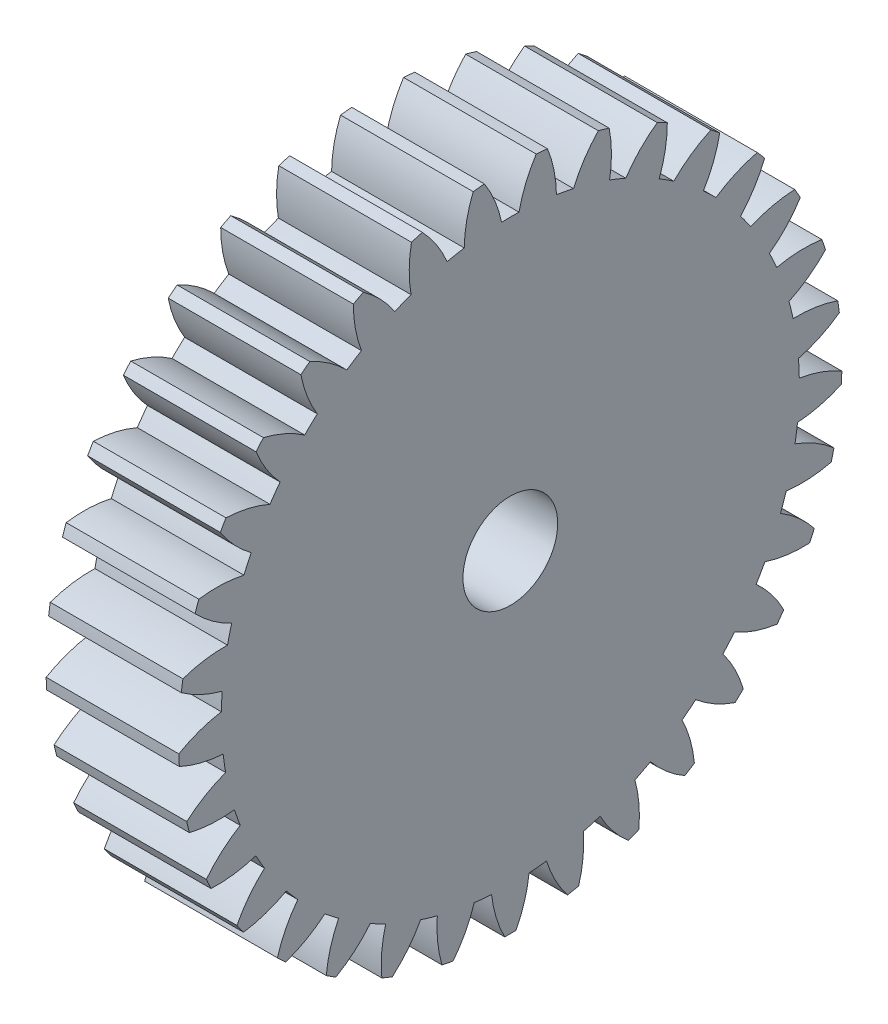
from build123d import *

# Parameters (mm, degrees)
BASPROSKE_W     = 7
BASPROSKE_H     = 17.5
TOOTHCUT_DEPTH  = 26.719642299
TEETHCUTS_COUNT = 33
TEETHCUTS_ANGLE = 349.090909091
BORSKE_R        = 2.5
BORE_DEPTH      = 50.0000508


with BuildPart() as part:
    # BasProSke → Base-Revolve (revolve)
    with BuildSketch(Plane(origin=(0, 0, 0), x_dir=(1, 0, 0), z_dir=(0, 1, 0)), mode=Mode.PRIVATE) as base_revolve_sk:
        with Locations((3.5, 8.75)):
            Rectangle(BASPROSKE_W, BASPROSKE_H)
    revolve(base_revolve_sk.sketch.rotate(Axis((-10, 0, 0), (1, 0, 0)), 180), axis=Axis((-10, 0, 0), (1, 0, 0)))

    # TooCutSke → ToothCut (cut, through all)
    with BuildSketch(Plane(origin=(0, 0, 0), x_dir=(0, 0, -1), z_dir=(1, 0, 0))):
        with BuildLine():
            ThreePointArc((0.460038855, 15.242059088), (0, 15.249), (-0.460038855, 15.242059088))
            ThreePointArc((-0.460038855, 15.242059088), (-0.818271128, 16.398913356), (-1.381851371, 17.470836613))
            ThreePointArc((-1.381851371, 17.470836613), (0, 17.5254), (1.381851371, 17.470836613))
            ThreePointArc((1.381851371, 17.470836613), (0.818271128, 16.398913356), (0.460038855, 15.242059088))
        make_face()
    toothcut = extrude(amount=TOOTHCUT_DEPTH, mode=Mode.SUBTRACT)

    # TeethCuts: ToothCut ×33 about axis
    teethcuts_axis = Axis((-10, 0, 0), (1, 0, 0))
    for i in range(1, TEETHCUTS_COUNT):
        add(toothcut.rotate(teethcuts_axis, i * TEETHCUTS_ANGLE / (TEETHCUTS_COUNT - 1)), mode=Mode.SUBTRACT)

    # BorSke → Bore (cut, symmetric)
    with BuildSketch(Plane(origin=(0, 0, 0), x_dir=(0, 0, -1), z_dir=(1, 0, 0))):
        with Locations(Location((0, 0, 0), (0, 0, 180))):
            Circle(BORSKE_R)
    extrude(amount=BORE_DEPTH, both=True, mode=Mode.SUBTRACT)


solid = part.part
